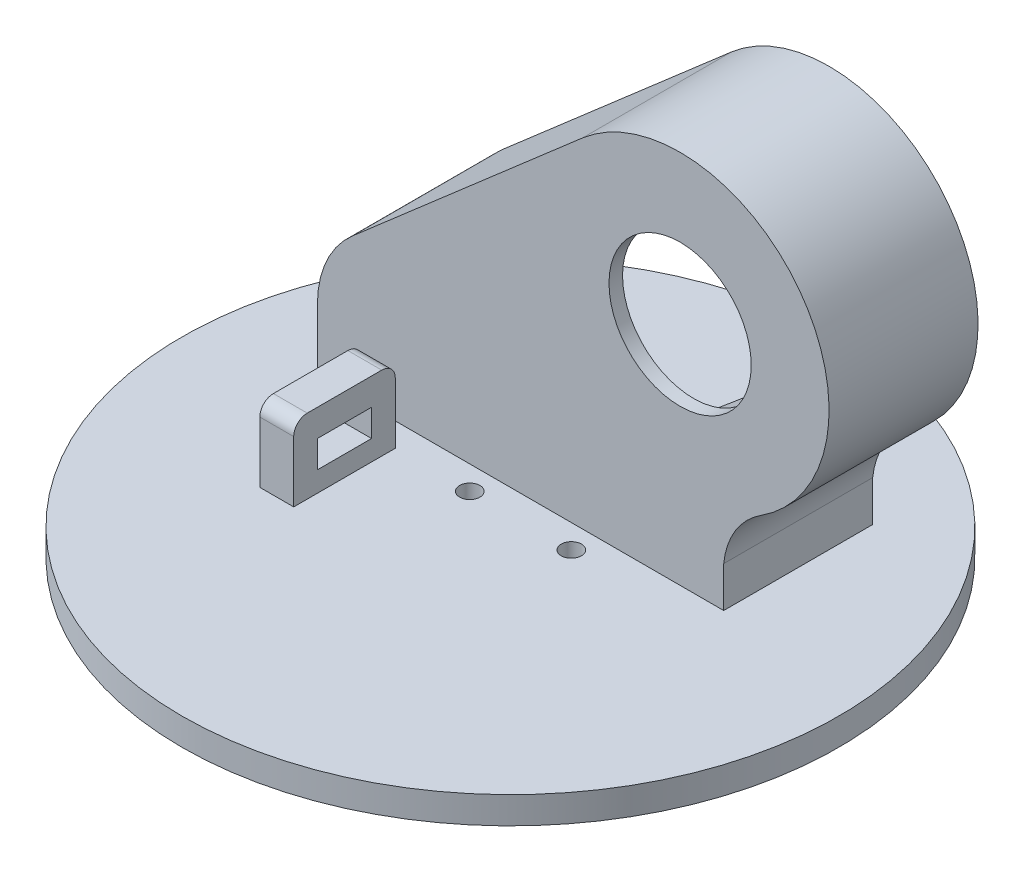
from build123d import *

# Parameters (mm, degrees)
SKETCH1_R               = 48.5
SKETCH1_R_2             = 1.5
SKETCH1_W               = 5
SKETCH1_H               = 15
BOSS_EXTRUDE1_DEPTH     = 4
SKETCH1_4_W             = 5
SKETCH1_4_H             = 15
BOSS_EXTRUDE2_DEPTH     = 15
FILLET1_R               = 2
EXTRUDE_THIN1_DEPTH     = 11
SKETCH3_4_R             = 10.5
BOSS_EXTRUDE3_DEPTH     = 11
CUT_EXTRUDE2_DEPTH      = 11
SKETCH8_R               = 1.5
CUT_EXTRUDE3_DEPTH      = 9
SKETCH9_W               = 8
SKETCH9_H               = 4
CUT_EXTRUDE4_DEPTH      = 26
CUT_EXTRUDE4_DEPTH_BACK = 73


with BuildPart() as part:
    # Sketch1 → Boss-Extrude1 (new body)
    with BuildSketch(Plane(origin=(0, 0, 0), x_dir=(1, 0, 0), z_dir=(0, 1, 0))):
        Circle(SKETCH1_R)
        with Locations((7.5, 1.5)):
            Circle(SKETCH1_R_2, mode=Mode.SUBTRACT)
        with Locations((-7.5, 1.5)):
            Circle(SKETCH1_R_2, mode=Mode.SUBTRACT)
        with Locations((-21, -6)):
            Rectangle(SKETCH1_W, SKETCH1_H, mode=Mode.SUBTRACT)
    extrude(amount=BOSS_EXTRUDE1_DEPTH)

    # Sketch1_4 → Boss-Extrude2 (add)
    with BuildSketch(Plane(origin=(0, 0, 0), x_dir=(1, 0, 0), z_dir=(0, 1, 0))):
        with Locations((-21, -6)):
            Rectangle(SKETCH1_4_W, SKETCH1_4_H)
    extrude(amount=BOSS_EXTRUDE2_DEPTH)

    # Fillet1
    fillet1_edges = [part.edges().sort_by_distance(p)[0] for p in [
        (-21, 15, -1.5),
        (-21, 15, 13.5),
    ]]
    fillet(fillet1_edges, radius=FILLET1_R)

    # Sketch3 → Extrude-Thin1 (add, symmetric)
    with BuildSketch(Plane.XY.offset(-16)):
        with BuildLine():
            Line((-33.5, 0), (-33.5, 13.162084514))
            ThreePointArc((-33.5, 13.162084514), (-32.148724822, 19.384006302), (-28.338358569, 24.484924294))
            Line((-28.338358569, 24.484924294), (5.63016077, 54))
            ThreePointArc((5.63016077, 54), (37.663321214, 50.588409815), (31.952020166, 18.884413917))
            ThreePointArc((31.952020166, 18.884413917), (28.210951689, 15.065108917), (26.5, 10))
            Line((26.5, 10), (26.5, 0))
            Line((26.5, 0), (16.5, 0))
            Line((16.5, 0), (16.5, 10.429751474))
            ThreePointArc((16.5, 10.429751474), (19.537286112, 20.046443985), (26.546444335, 27.297484102))
            ThreePointArc((26.546444335, 27.297484102), (29.661699452, 44.590572773), (12.189066483, 46.451440147))
            Line((12.189066483, 46.451440147), (-21.779452856, 16.936364441))
            ThreePointArc((-21.779452856, 16.936364441), (-23.049574941, 15.236058444), (-23.5, 13.162084514))
            Line((-23.5, 13.162084514), (-23.5, 0))
            Line((-23.5, 0), (-33.5, 0))
        make_face()
    extrude(amount=EXTRUDE_THIN1_DEPTH, both=True)

    # Sketch3_4 → Boss-Extrude3 (add)
    with BuildSketch(Plane.XY.offset(-16)):
        with BuildLine():
            Line((-33.5, 0), (-33.5, 13.162084514))
            ThreePointArc((-33.5, 13.162084514), (-32.148724822, 19.384006302), (-28.338358569, 24.484924294))
            Line((-28.338358569, 24.484924294), (5.63016077, 54))
            ThreePointArc((5.63016077, 54), (37.663321214, 50.588409815), (31.952020166, 18.884413917))
            ThreePointArc((31.952020166, 18.884413917), (28.210951689, 15.065108917), (26.5, 10))
            Line((26.5, 10), (26.5, 0))
            Line((26.5, 0), (-33.5, 0))
        make_face()
        with Locations((20.059753337, 37.393168323)):
            Circle(SKETCH3_4_R, mode=Mode.SUBTRACT)
    extrude(amount=BOSS_EXTRUDE3_DEPTH)

    # Sketch5 → Cut-Extrude2 (cut)
    with BuildSketch(Plane(origin=(0, 0, -27), x_dir=(-1, 0, 0), z_dir=(0, 0, -1))):
        with BuildLine():
            Line((-16.5, 4), (25.5, 4))
            ThreePointArc((25.5, 4), (22.632303684, 20.469705569), (12.81364714, 34))
            Line((12.81364714, 34), (-7.597832484, 51.735432044))
            ThreePointArc((-7.597832484, 51.735432044), (-35.262834685, 48.789058703), (-30.330347417, 21.408334972))
            ThreePointArc((-30.330347417, 21.408334972), (-21.973239319, 13.849736754), (-16.5, 4))
        make_face()
    extrude(amount=-CUT_EXTRUDE2_DEPTH, mode=Mode.SUBTRACT)

    # Sketch8 → Cut-Extrude3 (cut)
    with BuildSketch(Plane(origin=(0, 0, -16), x_dir=(-1, 0, 0), z_dir=(0, 0, -1))):
        with Locations((-34.764358033, 43.204760253)):
            Circle(SKETCH8_R)
        with Locations((-28.336481936, 50.865204684)):
            Circle(SKETCH8_R)
        with Locations((8.433651334, 20.011399419)):
            Circle(SKETCH8_R)
        with Locations((2.005775237, 12.350954988)):
            Circle(SKETCH8_R)
        Polygon((-36.322950361, 36.680130765), (-22.181622948, 53.533108514), (9.992243663, 26.536028907), (-4.14908375, 9.683051158), align=None)
    extrude(amount=-CUT_EXTRUDE3_DEPTH, mode=Mode.SUBTRACT)

    # Sketch9 → Cut-Extrude4 (cut, two sides)
    with BuildSketch(Plane.ZY.offset(23.5)) as cut_extrude4_sk:
        with Locations((6, 9)):
            Rectangle(SKETCH9_W, SKETCH9_H)
    extrude(amount=CUT_EXTRUDE4_DEPTH, mode=Mode.SUBTRACT)
    extrude(cut_extrude4_sk.sketch, amount=-CUT_EXTRUDE4_DEPTH_BACK, mode=Mode.SUBTRACT)


solid = part.part
